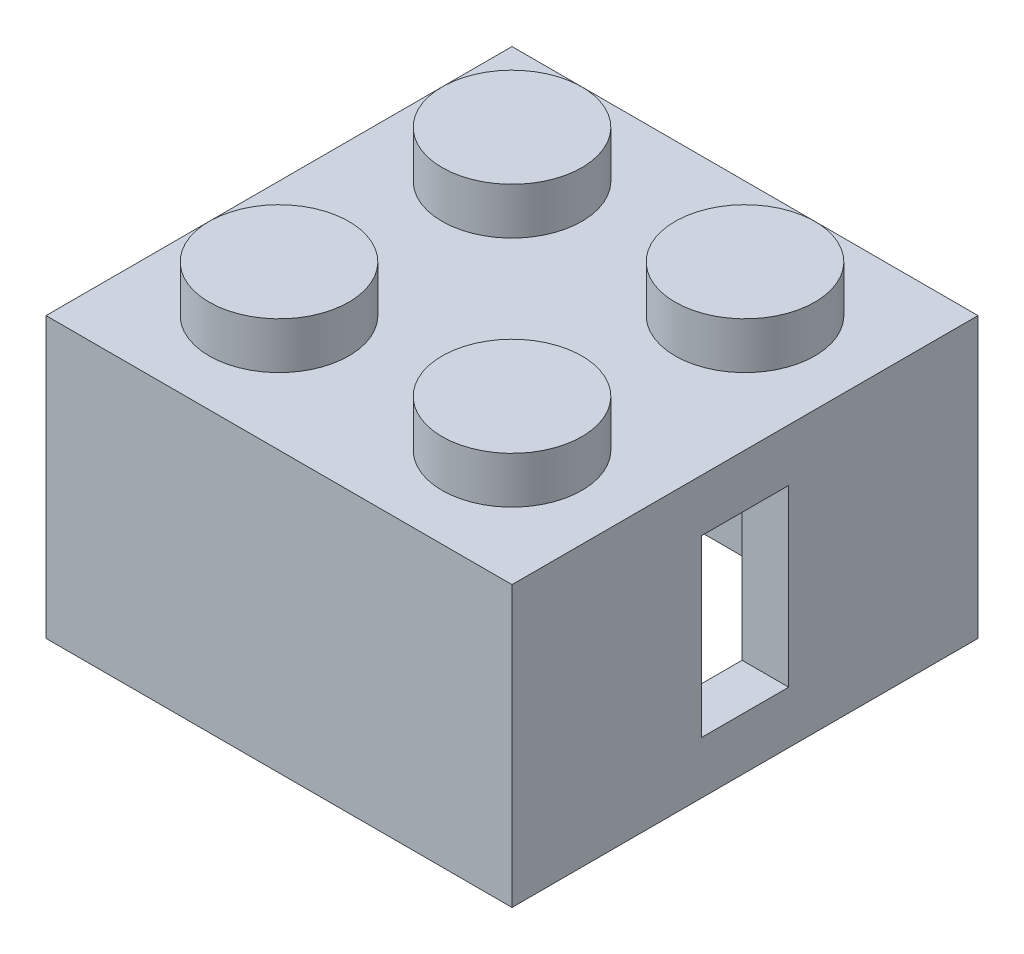
from build123d import *

# Parameters (mm, degrees)
SKETCH1_W           = 16
SKETCH1_H           = 16
SKETCH1_W_2         = 12.8
SKETCH1_H_2         = 12.8
BOSS_EXTRUDE1_DEPTH = 8
SKETCH2_W           = 16
SKETCH2_H           = 16
BOSS_EXTRUDE2_DEPTH = 1.6
SKETCH3_R           = 2.4
BOSS_EXTRUDE3_DEPTH = 1.6
SKETCH4_R           = 3.25
CUT_EXTRUDE1_DEPTH  = 1.6
SKETCH7_W           = 3
SKETCH7_H           = 6
CUT_EXTRUDE2_DEPTH  = 1.6


with BuildPart() as part:
    # Sketch1 → Boss-Extrude1 (new body)
    with BuildSketch(Plane(origin=(0, 0, 0), x_dir=(1, 0, 0), z_dir=(0, 1, 0))):
        with Locations((8, 8)):
            Rectangle(SKETCH1_W, SKETCH1_H)
        with Locations((8, 8)):
            Rectangle(SKETCH1_W_2, SKETCH1_H_2, mode=Mode.SUBTRACT)
    extrude(amount=BOSS_EXTRUDE1_DEPTH)

    # Sketch2 → Boss-Extrude2 (add)
    with BuildSketch(Plane(origin=(0, 8, 0), x_dir=(1, 0, 0), z_dir=(0, 1, 0))):
        with Locations((8, 8)):
            Rectangle(SKETCH2_W, SKETCH2_H)
    extrude(amount=BOSS_EXTRUDE2_DEPTH)

    # Sketch3 → Boss-Extrude3 (add)
    with BuildSketch(Plane(origin=(0, 9.6, 0), x_dir=(1, 0, 0), z_dir=(0, 1, 0))):
        with Locations((12, 4)):
            Circle(SKETCH3_R)
        with Locations((4, 4)):
            Circle(SKETCH3_R)
        with Locations((4, 12)):
            Circle(SKETCH3_R)
        with Locations((12, 12)):
            Circle(SKETCH3_R)
    extrude(amount=BOSS_EXTRUDE3_DEPTH)

    # Sketch4 → Cut-Extrude1 (cut)
    with BuildSketch(Plane.ZY):
        with Locations((-8, 4.8)):
            Circle(SKETCH4_R)
    extrude(amount=-CUT_EXTRUDE1_DEPTH, mode=Mode.SUBTRACT)

    # Sketch7 → Cut-Extrude2 (cut)
    with BuildSketch(Plane(origin=(16, 0, 0), x_dir=(0, 0, -1), z_dir=(1, 0, 0))):
        with Locations((8, 4.8)):
            Rectangle(SKETCH7_W, SKETCH7_H)
    extrude(amount=-CUT_EXTRUDE2_DEPTH, mode=Mode.SUBTRACT)


solid = part.part
